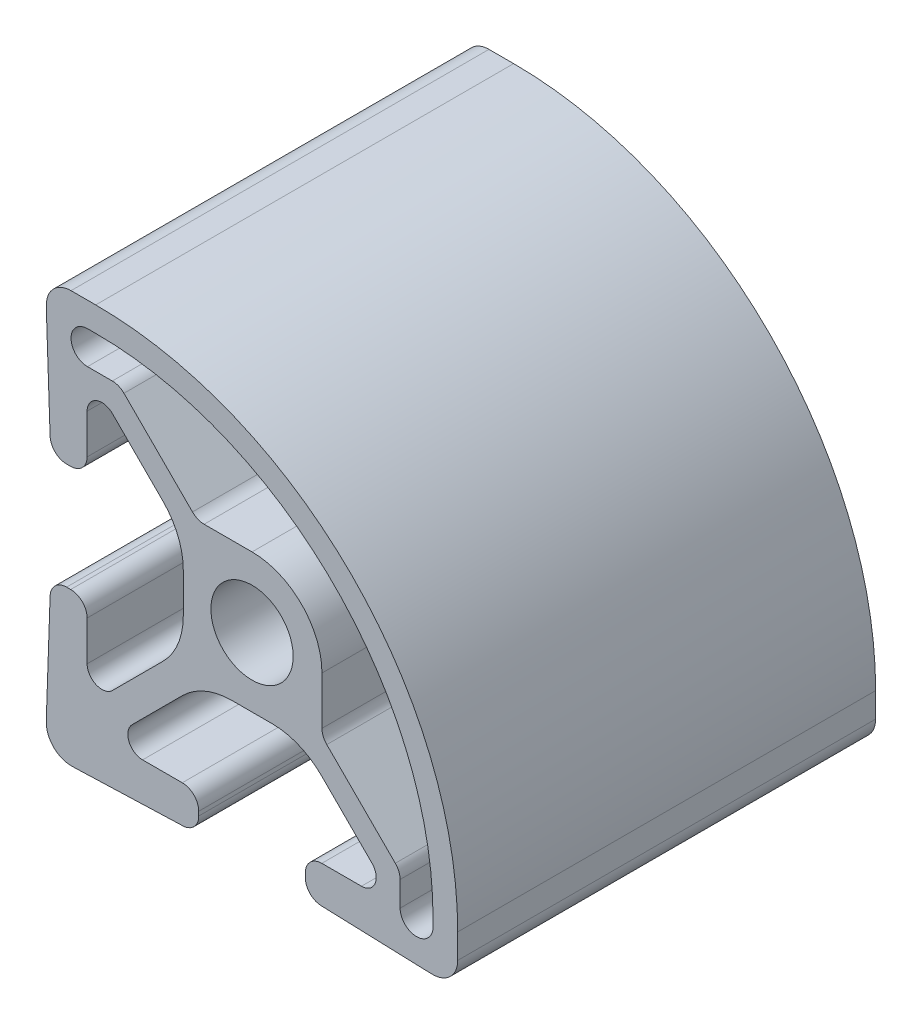
from build123d import *

# Parameters (mm, degrees)
SKETCH1_R      = 2.5
EXTRUDE1_DEPTH = 25.4


with BuildPart() as part:
    # Sketch1 → Extrude1 (new body)
    with BuildSketch(Plane.XY):
        with BuildLine():
            Line((1.22051236, -4.17896), (-1.22051236, -4.17896))
            ThreePointArc((-1.22051236, -4.17896), (-2.846916947, -4.502471987), (-4.22571618, -5.42375618))
            Line((-4.22571618, -5.42375618), (-7.286523897, -8.484563897))
            ThreePointArc((-7.286523897, -8.484563897), (-7.481619373, -9.465375089), (-6.650127794, -10.02096))
            Line((-6.650127794, -10.02096), (-4.24, -10.02096))
            ThreePointArc((-4.24, -10.02096), (-3.532893219, -10.313853219), (-3.24, -11.02096))
            Line((-3.24, -11.02096), (-3.24, -11.272405454))
            ThreePointArc((-3.24, -11.272405454), (-3.5206602, -11.967063824), (-4.205100503, -12.271796281))
            Line((-4.205100503, -12.271796281), (-10.74, -12.5))
            Line((-10.74, -12.5), (-11, -12.5))
            ThreePointArc((-11, -12.5), (-12.060660172, -12.060660172), (-12.5, -11))
            Line((-12.5, -11), (-12.5, -10.74))
            Line((-12.5, -10.74), (-12.271796281, -4.205100503))
            ThreePointArc((-12.271796281, -4.205100503), (-11.967063824, -3.5206602), (-11.272405454, -3.24))
            Line((-11.272405454, -3.24), (-11.02096, -3.24))
            ThreePointArc((-11.02096, -3.24), (-10.313853219, -3.532893219), (-10.02096, -4.24))
            Line((-10.02096, -4.24), (-10.02096, -6.650127794))
            ThreePointArc((-10.02096, -6.650127794), (-9.465375089, -7.481619373), (-8.484563897, -7.286523897))
            Line((-8.484563897, -7.286523897), (-5.42375618, -4.22571618))
            ThreePointArc((-5.42375618, -4.22571618), (-4.502471987, -2.846916947), (-4.17896, -1.22051236))
            Line((-4.17896, -1.22051236), (-4.17896, 1.22051236))
            ThreePointArc((-4.17896, 1.22051236), (-4.502471987, 2.846916947), (-5.42375618, 4.22571618))
            Line((-5.42375618, 4.22571618), (-8.484563897, 7.286523897))
            ThreePointArc((-8.484563897, 7.286523897), (-9.465375089, 7.481619373), (-10.02096, 6.650127794))
            Line((-10.02096, 6.650127794), (-10.02096, 4.24))
            ThreePointArc((-10.02096, 4.24), (-10.313853219, 3.532893219), (-11.02096, 3.24))
            Line((-11.02096, 3.24), (-11.272405454, 3.24))
            ThreePointArc((-11.272405454, 3.24), (-11.967063824, 3.5206602), (-12.271796281, 4.205100503))
            Line((-12.271796281, 4.205100503), (-12.5, 10.74))
            Line((-12.5, 10.74), (-12.5, 11))
            ThreePointArc((-12.5, 11), (-12.060660172, 12.060660172), (-11, 12.5))
            Line((-11, 12.5), (-9.5, 12.5))
            ThreePointArc((-9.5, 12.5), (6.056349186, 6.056349186), (12.5, -9.5))
            Line((12.5, -9.5), (12.5, -11))
            ThreePointArc((12.5, -11), (12.060660172, -12.060660172), (11, -12.5))
            Line((11, -12.5), (10.74, -12.5))
            Line((10.74, -12.5), (4.205100503, -12.271796281))
            ThreePointArc((4.205100503, -12.271796281), (3.5206602, -11.967063824), (3.24, -11.272405454))
            Line((3.24, -11.272405454), (3.24, -11.02096))
            ThreePointArc((3.24, -11.02096), (3.532893219, -10.313853219), (4.24, -10.02096))
            Line((4.24, -10.02096), (6.650127794, -10.02096))
            ThreePointArc((6.650127794, -10.02096), (7.481619373, -9.465375089), (7.286523897, -8.484563897))
            Line((7.286523897, -8.484563897), (4.22571618, -5.42375618))
            ThreePointArc((4.22571618, -5.42375618), (2.846916947, -4.502471987), (1.22051236, -4.17896))
        make_face()
        Circle(SKETCH1_R, mode=Mode.SUBTRACT)
        with BuildLine():
            Line((4.25, 0), (4.25, -2.912506094))
            ThreePointArc((4.25, -2.912506094), (4.326120467, -3.295189526), (4.542893219, -3.619612875))
            Line((4.542893219, -3.619612875), (8.707106781, -7.783826438))
            ThreePointArc((8.707106781, -7.783826438), (8.923879533, -8.108249786), (9, -8.490933219))
            Line((9, -8.490933219), (9, -10))
            ThreePointArc((9, -10), (10, -11), (11, -10))
            Line((11, -10), (11, -9.5))
            ThreePointArc((11, -9.5), (4.995689014, 4.995689014), (-9.5, 11))
            Line((-9.5, 11), (-10, 11))
            ThreePointArc((-10, 11), (-11, 10), (-10, 9))
            Line((-10, 9), (-8.490933219, 9))
            ThreePointArc((-8.490933219, 9), (-8.108249786, 8.923879533), (-7.783826438, 8.707106781))
            Line((-7.783826438, 8.707106781), (-3.619612875, 4.542893219))
            ThreePointArc((-3.619612875, 4.542893219), (-3.295189526, 4.326120467), (-2.912506094, 4.25))
            Line((-2.912506094, 4.25), (0, 4.25))
            ThreePointArc((0, 4.25), (3.00520382, 3.00520382), (4.25, 0))
        make_face(mode=Mode.SUBTRACT)
    extrude(amount=EXTRUDE1_DEPTH)


solid = part.part
